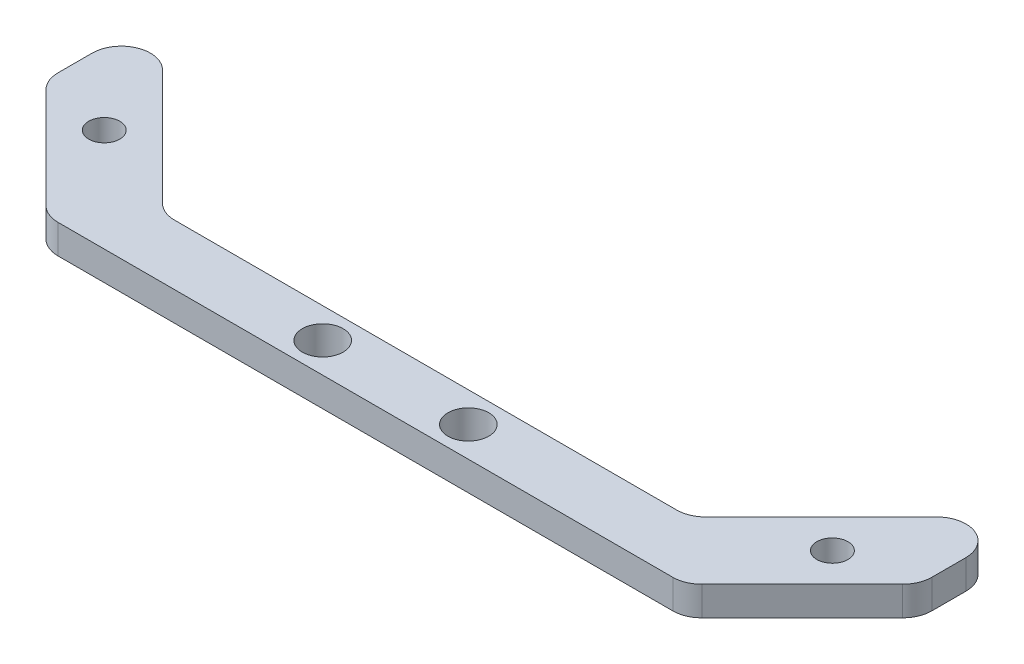
from build123d import *

# Parameters (mm, degrees)
SKETCH1_R           = 1.6
SKETCH1_R_2         = 2.1
BOSS_EXTRUDE1_DEPTH = 3
CUT_EXTRUDE1_DEPTH  = 4
FILLET1_R           = 3


with BuildPart() as part:
    # Sketch1 → Boss-Extrude1 (new body)
    with BuildSketch(Plane(origin=(0, 0, 0), x_dir=(1, 0, 0), z_dir=(0, 1, 0))):
        Polygon((0, 0), (0, 12), (15, -3), (75, -3), (90, 12), (90, 0), (75, -15), (15, -15), align=None)
        with Locations((7.5, -1.5)):
            Circle(SKETCH1_R, mode=Mode.SUBTRACT)
        with Locations((37.5, -9)):
            Circle(SKETCH1_R_2, mode=Mode.SUBTRACT)
        with Locations((82.5, -1.5)):
            Circle(SKETCH1_R, mode=Mode.SUBTRACT)
        with Locations((52.5, -9)):
            Circle(SKETCH1_R_2, mode=Mode.SUBTRACT)
    extrude(amount=BOSS_EXTRUDE1_DEPTH)

    # Sketch2 → Cut-Extrude1 (cut, through all)
    with BuildSketch(Plane(origin=(0, 3, 0), x_dir=(1, 0, 0), z_dir=(0, 1, 0))):
        Polygon((15, -3), (17.9, -5.9), (72.1, -5.9), (75, -3), align=None)
        Polygon((12.1, -12.1), (77.9, -12.1), (75, -15), (15, -15), align=None)
    extrude(amount=-CUT_EXTRUDE1_DEPTH, mode=Mode.SUBTRACT)

    # Fillet1
    fillet1_edges = [part.edges().sort_by_distance(p)[0] for p in [
        (0, 1.5, 0),
        (0, 1.5, -12),
        (90, 1.5, -12),
        (90, 1.5, 0),
        (72.1, 1.5, 5.9),
        (17.9, 1.5, 5.9),
        (12.1, 1.5, 12.1),
        (77.9, 1.5, 12.1),
    ]]
    fillet(fillet1_edges, radius=FILLET1_R)


solid = part.part
